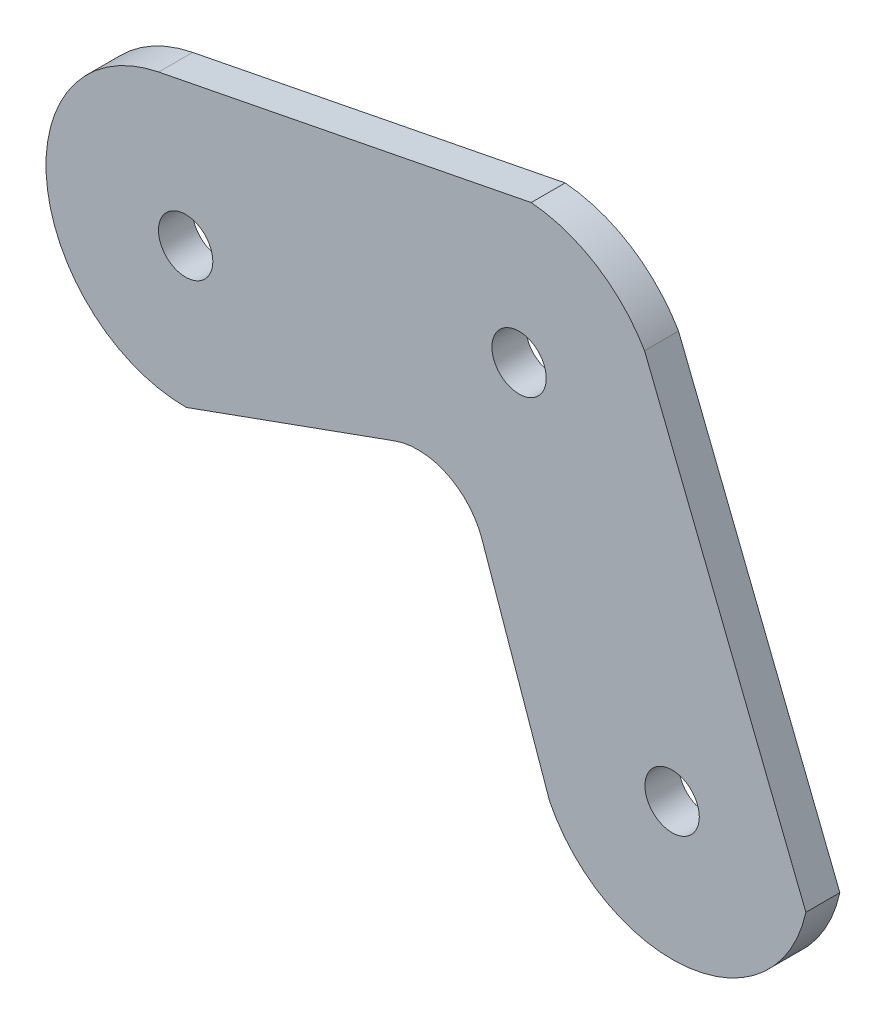
from build123d import *

# Parameters (mm, degrees)
EXTRUDE_1_DEPTH = 5


with BuildPart() as part:
    # 草图1 → 凸台-拉伸1 (new body)
    with BuildSketch(Plane.XY):
        with BuildLine():
            ThreePointArc((39.676398778, 63.242940301), (32.116908157, 65.519966744), (40.007886711, 65.771373436))
            Line((40.007886711, 65.771373436), (81.219528006, 73.870794511))
            ThreePointArc((81.219528006, 73.870794511), (84.756936789, 78.623353252), (89.144446225, 74.642167947))
            ThreePointArc((89.144446225, 74.642167947), (88.550754884, 72.545250848), (86.945915565, 71.070794511))
            Line((86.945915565, 71.070794511), (105.861343633, 33.571373436))
            ThreePointArc((105.861343633, 33.571373436), (109.759730072, 33.406308659), (111.662812973, 30))
            ThreePointArc((111.662812973, 30), (106.761070533, 26.102967723), (104.069382688, 31.757059699))
            Line((104.069382688, 31.757059699), (82.109783132, 42.494523437))
            Line((82.109783132, 42.494523437), (89.614398352, 21.050380059))
            ThreePointArc((89.614398352, 21.050380059), (110.127424639, 10.005834432), (127.344312529, 25.70121614))
            Line((127.344312529, 25.70121614), (103.609378398, 85.394704235))
            ThreePointArc((103.609378398, 85.394704235), (96.558072376, 92.705940943), (86.927534136, 95.93515633))
            Line((86.927534136, 95.93515633), (32.120142981, 85.163730465))
            ThreePointArc((32.120142981, 85.163730465), (15.634853586, 62.961714189), (36.178446258, 44.450768961))
            Line((36.178446258, 44.450768961), (60.302024626, 53.157742297))
            Line((60.302024626, 53.157742297), (39.676398778, 63.242940301))
        make_face()
        with BuildLine():
            Line((81.219528006, 73.870794511), (40.007886711, 65.771373436))
            ThreePointArc((40.007886711, 65.771373436), (40.064153798, 65.387509436), (40.082968492, 65))
            ThreePointArc((40.082968492, 65), (39.98000077, 64.098257559), (39.676398778, 63.242940301))
            Line((39.676398778, 63.242940301), (60.302024626, 53.157742297))
            Line((60.302024626, 53.157742297), (66.852758603, 55.522112342))
            ThreePointArc((66.852758603, 55.522112342), (74.542251323, 55.146923882), (79.686411635, 49.419212353))
            Line((79.686411635, 49.419212353), (82.109783132, 42.494523437))
            Line((82.109783132, 42.494523437), (104.069382688, 31.757059699))
            ThreePointArc((104.069382688, 31.757059699), (104.816909062, 32.810841675), (105.861343633, 33.571373436))
            Line((105.861343633, 33.571373436), (86.945915565, 71.070794511))
            ThreePointArc((86.945915565, 71.070794511), (83.387386526, 71.048737661), (81.219528006, 73.870794511))
        make_face()
    extrude(amount=EXTRUDE_1_DEPTH)


solid = part.part
